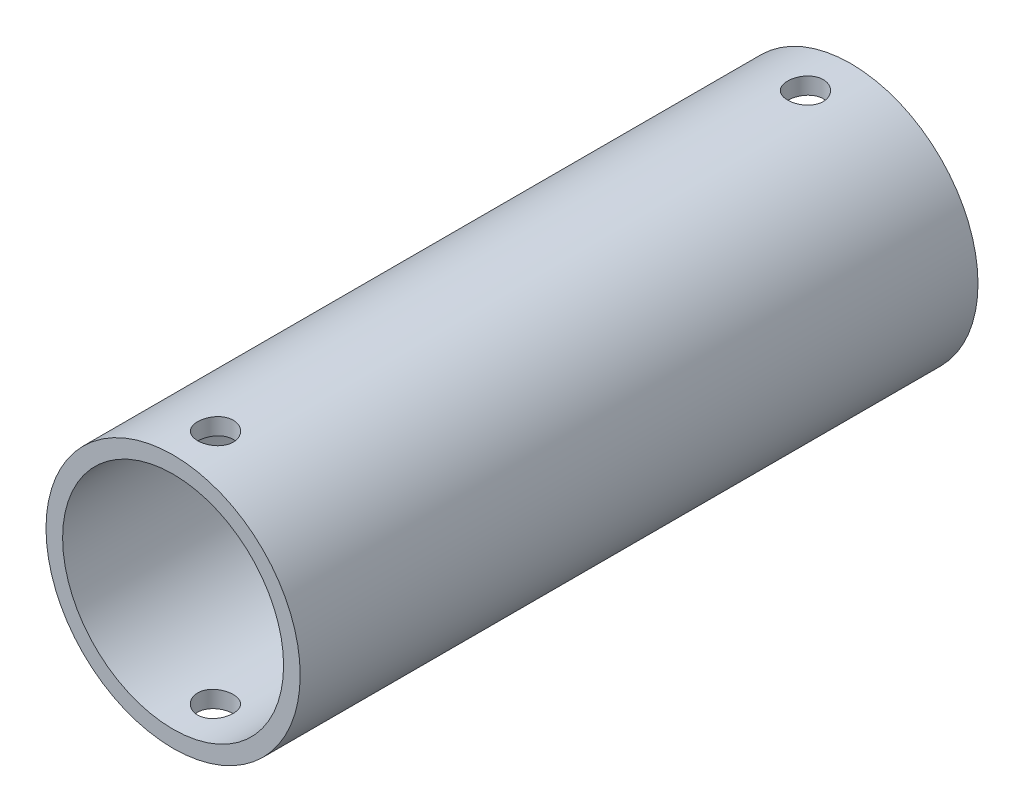
from build123d import *

# Parameters (mm, degrees)
SKETCH1_R               = 9.525
SKETCH1_R_2             = 8.2804
BOSS_EXTRUDE1_DEPTH     = 50.8
SKETCH2_R               = 1.3335
CUT_EXTRUDE1_DEPTH      = 10.525
CUT_EXTRUDE1_DEPTH_BACK = 10.525


with BuildPart() as part:
    # Sketch1 → Boss-Extrude1 (new body)
    with BuildSketch(Plane.XY):
        Circle(SKETCH1_R)
        Circle(SKETCH1_R_2, mode=Mode.SUBTRACT)
    extrude(amount=BOSS_EXTRUDE1_DEPTH)

    # Sketch2 → Cut-Extrude1 (cut, two sides)
    with BuildSketch(Plane(origin=(0, 0, 0), x_dir=(1, 0, 0), z_dir=(0, 1, 0))) as cut_extrude1_sk:
        with Locations((0, -47.625)):
            Circle(SKETCH2_R)
        with Locations((0, -3.407603683)):
            Circle(SKETCH2_R)
    extrude(amount=CUT_EXTRUDE1_DEPTH, mode=Mode.SUBTRACT)
    extrude(cut_extrude1_sk.sketch, amount=-CUT_EXTRUDE1_DEPTH_BACK, mode=Mode.SUBTRACT)


solid = part.part
